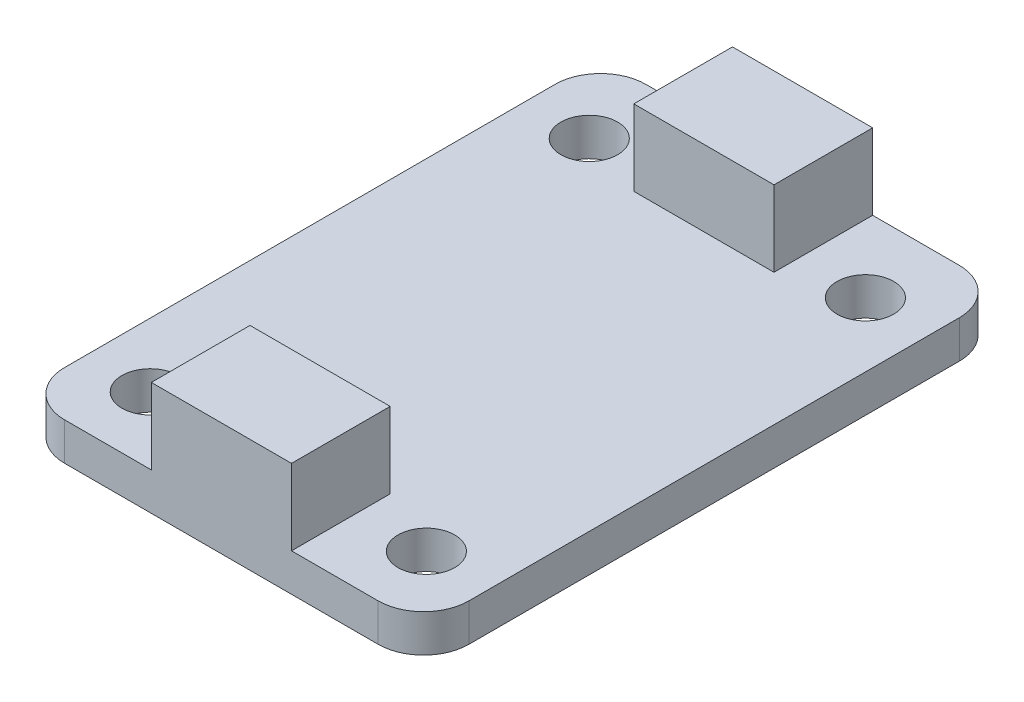
from build123d import *

# Parameters (mm, degrees)
SKETCH1_W           = 17.82
SKETCH1_H           = 25.62
BOSS_EXTRUDE1_DEPTH = 1.66
SKETCH2_W           = 6.18
SKETCH2_H           = 4.35
BOSS_EXTRUDE2_DEPTH = 5
FILLET1_R           = 2
HOLE1_D             = 2.5


with BuildPart() as part:
    # Sketch1 → Boss-Extrude1 (new body)
    with BuildSketch(Plane(origin=(0, 0, 0), x_dir=(1, 0, 0), z_dir=(0, 1, 0))):
        with Locations((-1.487037037, -0.58962963)):
            Rectangle(SKETCH1_W, SKETCH1_H)
    extrude(amount=BOSS_EXTRUDE1_DEPTH)

    # Sketch2 → Boss-Extrude2 (add)
    with BuildSketch(Plane(origin=(0, 0, 0), x_dir=(-1, 0, 0), z_dir=(0, -1, 0))):
        with Locations((1.487037037, -11.22462963)):
            Rectangle(SKETCH2_W, SKETCH2_H)
        with Locations((1.487037037, 10.04537037)):
            Rectangle(SKETCH2_W, SKETCH2_H)
    extrude(amount=-BOSS_EXTRUDE2_DEPTH)

    # Fillet1
    fillet1_edges = [part.edges().sort_by_distance(p)[0] for p in [
        (-10.397037037, 0.83, -12.22037037),
        (7.422962963, 0.83, -12.22037037),
        (7.422962963, 0.83, 13.39962963),
        (-10.397037037, 0.83, 13.39962963),
    ]]
    fillet(fillet1_edges, radius=FILLET1_R)

    # Hole1 (through all)
    with Locations(Plane(origin=(0, 1.66, 0), x_dir=(1, 0, 0), z_dir=(0, 1, 0))):
        with Locations((4.591727838, -10.44356219), (-7.580024265, -10.44356219), (-7.580024265, 8.909603349), (4.591727838, 8.909603349)):
            Hole(HOLE1_D / 2)


solid = part.part
